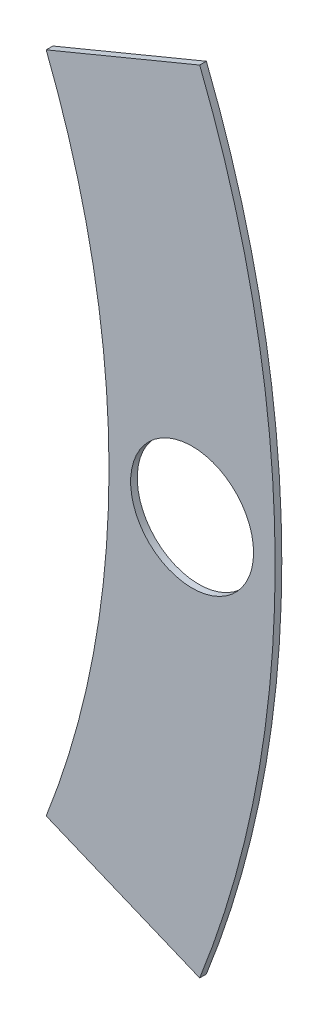
from build123d import *

# Parameters (mm, degrees)
SKETCH4_R           = 82.042
BOSS_EXTRUDE2_DEPTH = 0.508
SKETCH5_R           = 69.342
CUT_EXTRUDE5_DEPTH  = 1.508
SKETCH6_R           = 4.699
CUT_EXTRUDE6_DEPTH  = 1.508
SKETCH8_OUTSIDE_W   = 212.494
SKETCH8_OUTSIDE_H   = 212.494
CUT_EXTRUDE11_DEPTH = 1.508


with BuildPart() as part:
    # Sketch4 → Boss-Extrude2 (new body)
    with BuildSketch(Plane.XY):
        Circle(SKETCH4_R)
    extrude(amount=BOSS_EXTRUDE2_DEPTH)

    # Sketch5 → Cut-Extrude5 (cut, through all)
    with BuildSketch(Plane.XY.offset(0.508)):
        Circle(SKETCH5_R)
    extrude(amount=-CUT_EXTRUDE5_DEPTH, mode=Mode.SUBTRACT)

    # Sketch6 → Cut-Extrude6 (cut, through all)
    with BuildSketch(Plane.XY.offset(0.508)):
        with Locations((75.692, 0)):
            Circle(SKETCH6_R)
    extrude(amount=-CUT_EXTRUDE6_DEPTH, mode=Mode.SUBTRACT)

    # Sketch8 outside → Cut-Extrude11 (cut, through all)
    with BuildSketch(Plane.XY.offset(0.508)):
        Rectangle(SKETCH8_OUTSIDE_W, SKETCH8_OUTSIDE_H)
        with BuildLine():
            Line((64.538916848, -25.358256565), (76.273850543, -30.219025255))
            ThreePointArc((76.273850543, -30.219025255), (82.042, 0), (76.273850543, 30.219025255))
            Line((76.273850543, 30.219025255), (64.538916848, 25.358256565))
            ThreePointArc((64.538916848, 25.358256565), (69.342, 0), (64.538916848, -25.358256565))
        make_face(mode=Mode.SUBTRACT)
    extrude(amount=-CUT_EXTRUDE11_DEPTH, mode=Mode.SUBTRACT)


solid = part.part
